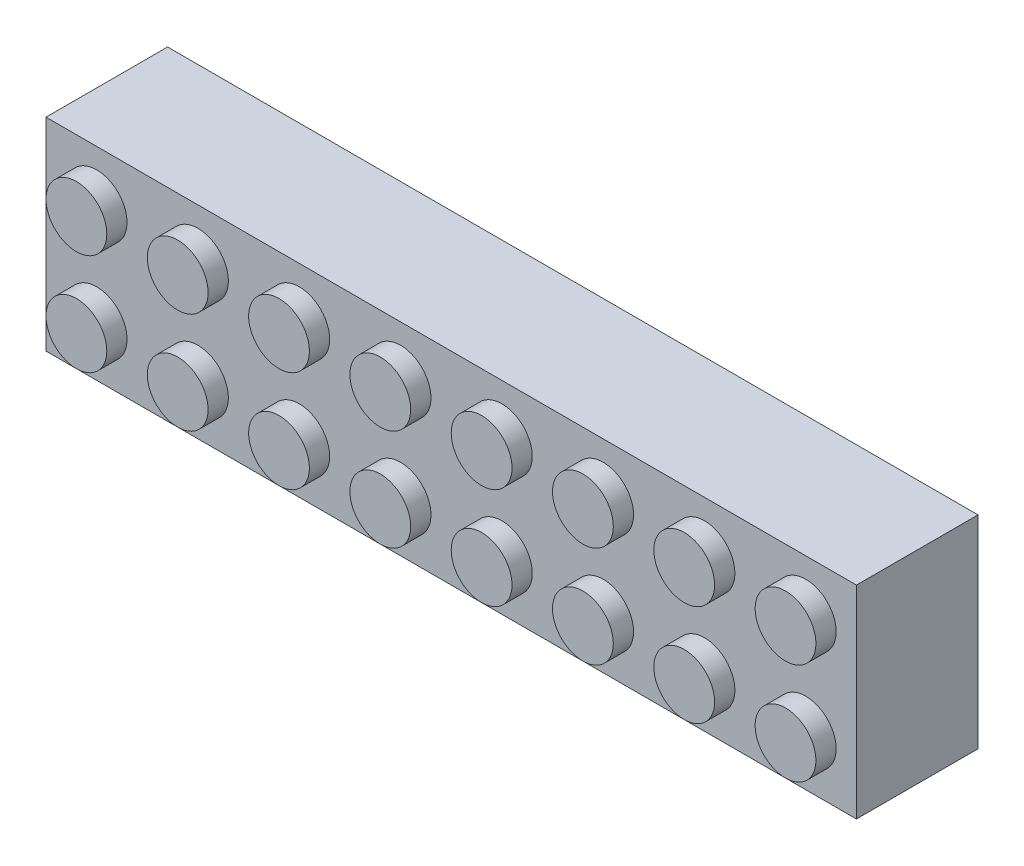
from build123d import *

# Parameters (mm, degrees)
SKETCH1_W            = 64
SKETCH1_H            = 16
BOSS_EXTRUDE1_DEPTH  = 9.6
SKETCH2_R            = 2.4
BOSS_EXTRUDE2_DEPTH  = 1.6
LPATTERN1_COUNT      = 8
LPATTERN1_PITCH      = 8
LPATTERN1_COUNT_DIR2 = 2
LPATTERN1_PITCH_DIR2 = 8
SHELL1_T             = -1.6
SKETCH3_R            = 3.256
SKETCH3_R_2          = 2.4
BOSS_EXTRUDE3_DEPTH  = 8
LPATTERN2_COUNT      = 7
LPATTERN2_PITCH      = 8


with BuildPart() as part:
    # Sketch1 → Boss-Extrude1 (new body)
    with BuildSketch(Plane.XY):
        with Locations((32, 8)):
            Rectangle(SKETCH1_W, SKETCH1_H)
    extrude(amount=BOSS_EXTRUDE1_DEPTH)

    # Sketch2 → Boss-Extrude2 (add)
    with BuildSketch(Plane.XY.offset(9.6)):
        with Locations((4, 12)):
            Circle(SKETCH2_R)
    boss_extrude2 = extrude(amount=BOSS_EXTRUDE2_DEPTH)

    # LPattern1: Boss-Extrude2 8 × 2
    with Locations(*[(i * LPATTERN1_PITCH, -j * LPATTERN1_PITCH_DIR2, 0) for i in range(LPATTERN1_COUNT) for j in range(LPATTERN1_COUNT_DIR2) if (i, j) != (0, 0)]):
        add(boss_extrude2)

    # Shell1
    shell1_openings = [part.faces().sort_by_distance(p)[0] for p in [
        (32, 8, 0),
    ]]
    offset(amount=SHELL1_T, openings=shell1_openings, kind=Kind.INTERSECTION)

    # Sketch3 → Boss-Extrude3 (add)
    with BuildSketch(Plane(origin=(0, 0, 8), x_dir=(-1, 0, 0), z_dir=(0, 0, -1))):
        with Locations((-8, 8)):
            Circle(SKETCH3_R)
        with Locations((-8, 8)):
            Circle(SKETCH3_R_2, mode=Mode.SUBTRACT)
    boss_extrude3 = extrude(amount=BOSS_EXTRUDE3_DEPTH)

    # LPattern2: Boss-Extrude3 ×7
    with Locations(*[(i * LPATTERN2_PITCH, 0, 0) for i in range(1, LPATTERN2_COUNT)]):
        add(boss_extrude3)


solid = part.part
